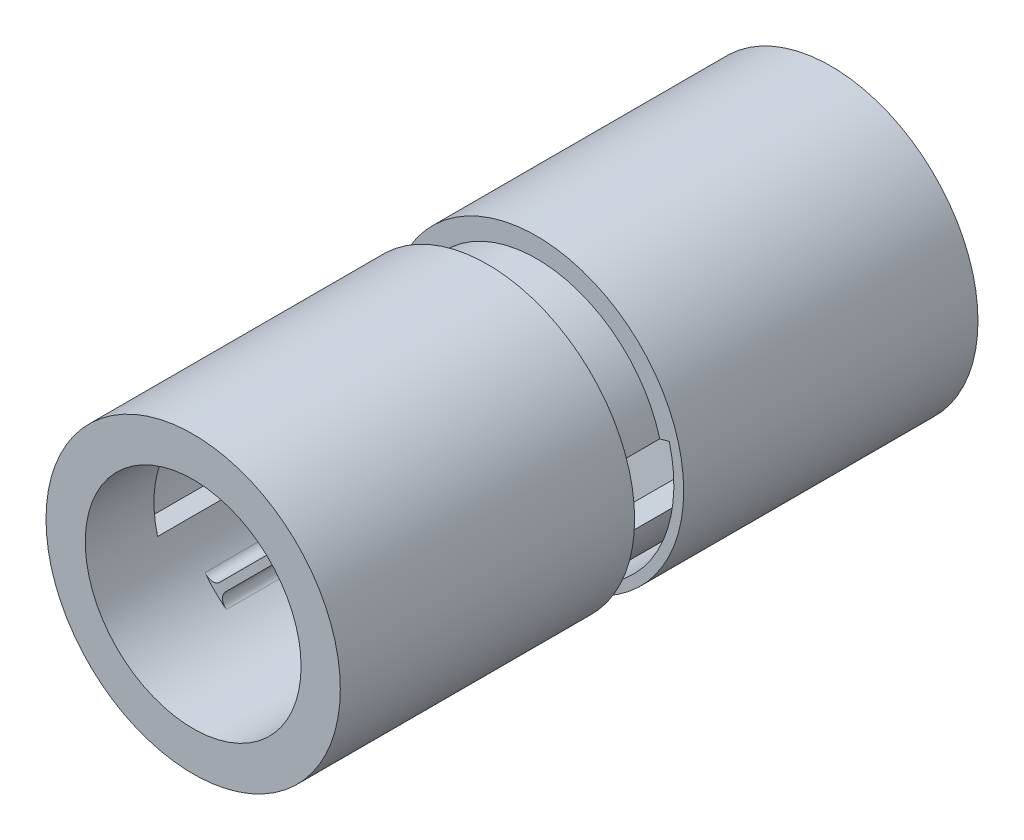
from build123d import *

# Parameters (mm, degrees)
SKETCH1_R                = 15
BOSS_EXTRUDE1_DEPTH      = 45
SKETCH2_R                = 15
SKETCH2_R_2              = 13
CUT_EXTRUDE1_DEPTH       = 25
BOSS_EXTRUDE4_DEPTH      = 10
SKETCH6_R                = 15
BOSS_EXTRUDE5_DEPTH      = 20
BOSS_EXTRUDE6_DEPTH      = 45
BOSS_EXTRUDE7_DEPTH      = 11.5
BOSS_EXTRUDE7_DEPTH_BACK = 11.5
FILLET1_R                = 1
SKETCH9_R                = 15
BOSS_EXTRUDE8_DEPTH      = 10
BOSS_EXTRUDE9_DEPTH      = 7
SKETCH11_R               = 15
BOSS_EXTRUDE10_DEPTH     = 10
BOSS_EXTRUDE11_DEPTH     = 7


with BuildPart() as part:
    # Sketch1 → Boss-Extrude1 (new body)
    with BuildSketch(Plane.XY):
        Circle(SKETCH1_R)
        with BuildLine():
            Line((-10.625184089, -2.847009496), (-13.522961568, -3.623466631))
            ThreePointArc((-13.522961568, -3.623466631), (0, 14), (13.522961568, -3.623466631))
            Line((13.522961568, -3.623466631), (10.625184089, -2.847009496))
            ThreePointArc((10.625184089, -2.847009496), (0, -11), (-10.625184089, -2.847009496))
        make_face(mode=Mode.SUBTRACT)
    extrude(amount=BOSS_EXTRUDE1_DEPTH)

    # Sketch2 → Cut-Extrude1 (cut)
    with BuildSketch(Plane(origin=(0, 0, 0), x_dir=(-1, 0, 0), z_dir=(0, 0, -1))):
        Circle(SKETCH2_R)
        Circle(SKETCH2_R_2, mode=Mode.SUBTRACT)
    extrude(amount=-CUT_EXTRUDE1_DEPTH, mode=Mode.SUBTRACT)

    # Sketch5 → Boss-Extrude4 (add)
    with BuildSketch(Plane.XY.offset(45)):
        Polygon((-7.495331881, -8.061017306), (8.061017306, 7.495331881), (7.495331881, 8.061017306), (-8.061017306, -7.495331881), align=None)
    boss_extrude4 = extrude(amount=-BOSS_EXTRUDE4_DEPTH)

    # Mirror1: Boss-Extrude4 across plane
    add(boss_extrude4.mirror(Plane.XY.offset(22.5)))

    # Sketch6 → Boss-Extrude5 (add)
    with BuildSketch(Plane(origin=(0, 0, 0), x_dir=(-1, 0, 0), z_dir=(0, 0, -1))):
        Circle(SKETCH6_R)
        with BuildLine():
            Line((10.625184089, 2.847009496), (13.522961568, 3.623466631))
            ThreePointArc((13.522961568, 3.623466631), (0, -14), (-13.522961568, 3.623466631))
            Line((-13.522961568, 3.623466631), (-10.625184089, 2.847009496))
            ThreePointArc((-10.625184089, 2.847009496), (0, 11), (10.625184089, 2.847009496))
        make_face(mode=Mode.SUBTRACT)
    extrude(amount=-BOSS_EXTRUDE5_DEPTH)

    # Sketch7 → Boss-Extrude6 (add)
    with BuildSketch(Plane(origin=(0, 0, 0), x_dir=(-1, 0, 0), z_dir=(0, 0, -1))):
        with BuildLine():
            Line((-12.557035742, 3.364647586), (-10.625184089, 2.847009496))
            ThreePointArc((-10.625184089, 2.847009496), (0, 11), (10.625184089, 2.847009496))
            Line((10.625184089, 2.847009496), (12.557035742, 3.364647586))
            ThreePointArc((12.557035742, 3.364647586), (0, 13), (-12.557035742, 3.364647586))
        make_face()
    extrude(amount=-BOSS_EXTRUDE6_DEPTH)

    # Sketch8 → Boss-Extrude7 (add, two sides)
    with BuildSketch(Plane.XY.offset(22.5)) as boss_extrude7_sk:
        Polygon((8.061017306, -7.495331881), (7.495331881, -8.061017306), (-8.061017306, 7.495331881), (-7.495331881, 8.061017306), align=None)
    extrude(amount=BOSS_EXTRUDE7_DEPTH)
    extrude(boss_extrude7_sk.sketch, amount=-BOSS_EXTRUDE7_DEPTH_BACK)

    # Fillet1
    fillet1_edges = [part.edges().sort_by_distance(p)[0] for p in [
        (7.490187585, 8.05587301, 40),
        (8.05587301, 7.490187585, 40),
        (-8.05587301, 7.490187585, 22.5),
        (-7.490187585, 8.05587301, 22.5),
        (8.05587301, -7.490187585, 22.5),
        (7.490187585, -8.05587301, 22.5),
        (-7.490187585, -8.05587301, 40),
        (-8.05587301, -7.490187585, 40),
        (-8.05587301, -7.490187585, 5),
        (-7.490187585, -8.05587301, 5),
        (8.05587301, 7.490187585, 5),
        (7.490187585, 8.05587301, 5),
    ]]
    fillet(fillet1_edges, radius=FILLET1_R)

    # Sketch9 → Boss-Extrude8 (add)
    with BuildSketch(Plane.XY.offset(45)):
        Circle(SKETCH9_R)
        with BuildLine():
            Line((13.522961568, -3.623466631), (10.625184089, -2.847009496))
            ThreePointArc((10.625184089, -2.847009496), (0, -11), (-10.625184089, -2.847009496))
            Line((-10.625184089, -2.847009496), (-13.522961568, -3.623466631))
            ThreePointArc((-13.522961568, -3.623466631), (0, 14), (13.522961568, -3.623466631))
        make_face(mode=Mode.SUBTRACT)
    extrude(amount=BOSS_EXTRUDE8_DEPTH)

    # Sketch10 → Boss-Extrude9 (add)
    with BuildSketch(Plane.XY.offset(55)):
        with BuildLine():
            Line((-13.522961568, -3.623466631), (-10.625184089, -2.847009496))
            ThreePointArc((-10.625184089, -2.847009496), (0, 11), (10.625184089, -2.847009496))
            Line((10.625184089, -2.847009496), (13.522961568, -3.623466631))
            ThreePointArc((13.522961568, -3.623466631), (0, 14), (-13.522961568, -3.623466631))
        make_face()
    extrude(amount=-BOSS_EXTRUDE9_DEPTH)

    # Sketch11 → Boss-Extrude10 (add)
    with BuildSketch(Plane(origin=(0, 0, 0), x_dir=(-1, 0, 0), z_dir=(0, 0, -1))):
        Circle(SKETCH11_R)
        with BuildLine():
            Line((10.625184089, 2.847009496), (13.522961568, 3.623466631))
            ThreePointArc((13.522961568, 3.623466631), (0, -14), (-13.522961568, 3.623466631))
            Line((-13.522961568, 3.623466631), (-10.625184089, 2.847009496))
            ThreePointArc((-10.625184089, 2.847009496), (0, 11), (10.625184089, 2.847009496))
        make_face(mode=Mode.SUBTRACT)
    extrude(amount=BOSS_EXTRUDE10_DEPTH)

    # Sketch12 → Boss-Extrude11 (add)
    with BuildSketch(Plane(origin=(0, 0, -10), x_dir=(-1, 0, 0), z_dir=(0, 0, -1))):
        with BuildLine():
            Line((13.522961568, 3.623466631), (10.625184089, 2.847009496))
            ThreePointArc((10.625184089, 2.847009496), (0, -11), (-10.625184089, 2.847009496))
            Line((-10.625184089, 2.847009496), (-13.522961568, 3.623466631))
            ThreePointArc((-13.522961568, 3.623466631), (0, -14), (13.522961568, 3.623466631))
        make_face()
    extrude(amount=-BOSS_EXTRUDE11_DEPTH)


solid = part.part
